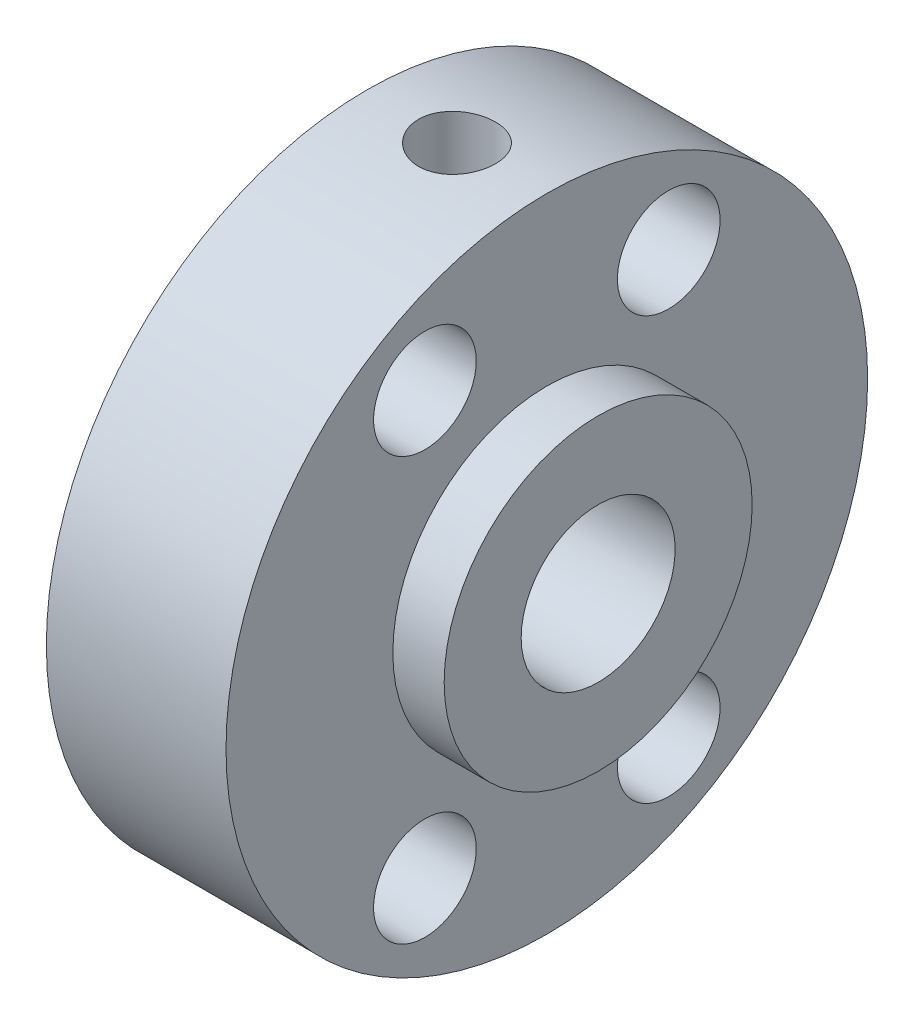
from build123d import *

# Parameters (mm, degrees)
ESQUISSE2_R             = 2
ENL_V_MAT_EXTRU_1_DEPTH = 8
ESQUISSE3_R             = 1.5
ENL_V_MAT_EXTRU_2_DEPTH = 30


with BuildPart() as part:
    # Esquisse1 → Révolution1 (revolve)
    with BuildSketch(Plane.XY):
        Polygon((0, 3), (0, 12.5), (7, 12.5), (7, 6), (9, 6), (9, 3), align=None)
    revolve(axis=Axis((0, 0, 0), (1, 0, 0)))

    # Esquisse2 → Enlèv. mat.-Extru.1 (cut, through all)
    with BuildSketch(Plane(origin=(7, 0, 0), x_dir=(0, 0, -1), z_dir=(1, 0, 0))):
        with Locations((-4.75, 8.227241336)):
            Circle(ESQUISSE2_R)
        with Locations((4.75, 8.227241336)):
            Circle(ESQUISSE2_R)
        with Locations((-4.75, -8.227241336)):
            Circle(ESQUISSE2_R)
        with Locations((4.75, -8.227241336)):
            Circle(ESQUISSE2_R)
    extrude(amount=-ENL_V_MAT_EXTRU_1_DEPTH, mode=Mode.SUBTRACT)

    # Esquisse3 → Enlèv. mat.-Extru.2 (cut)
    with BuildSketch(Plane(origin=(0, 0, 0), x_dir=(1, 0, 0), z_dir=(0, 1, 0))):
        with Locations((3.5, 0)):
            Circle(ESQUISSE3_R)
    extrude(amount=ENL_V_MAT_EXTRU_2_DEPTH, mode=Mode.SUBTRACT)


solid = part.part
